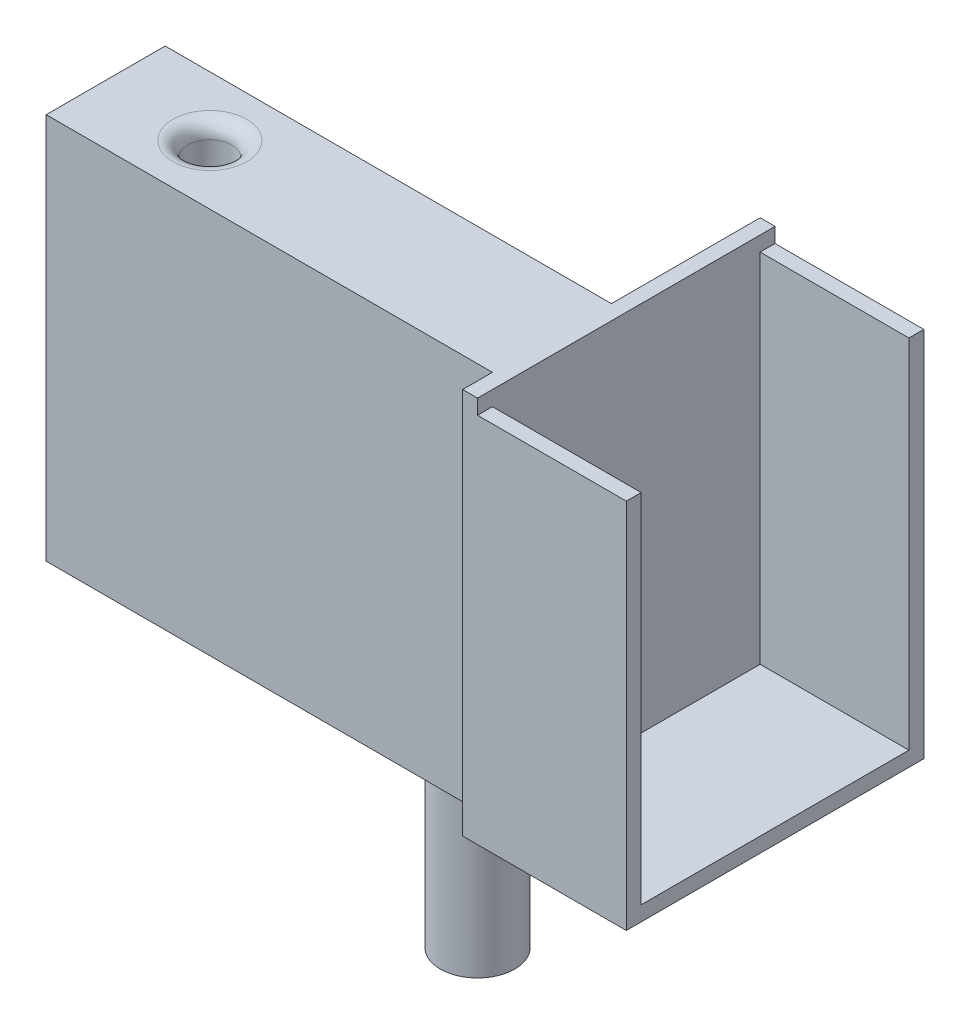
from build123d import *

# Parameters (mm, degrees)
SKETCH1_W                      = 76.2
SKETCH1_H                      = 66.04
BOSS_EXTRUDE1_DEPTH            = 20.32
SKETCH2_R                      = 3.749999993
CUT_EXTRUDE1_DEPTH             = 57.15
SKETCH4_W                      = 8
SKETCH4_H                      = 8
CUT_EXTRUDE4_DEPTH             = 5.08
FILLET2_R                      = 2.54
SKETCH5_W                      = 50.8
SKETCH5_H                      = 66.04
BOSS_EXTRUDE2_DEPTH            = 2.54
BOSS_EXTRUDE3_DEPTH            = 25.4
SKETCH3_W                      = 14
SKETCH3_H                      = 7
CUT_EXTRUDE5_DEPTH             = 73.66
CUT_EXTRUDE5_DIRECTION_2_REACH = 29.94
SKETCH7_R                      = 6.35
BOSS_EXTRUDE4_DEPTH            = 30.48


with BuildPart() as part:
    # Sketch1 → Boss-Extrude1 (new body)
    with BuildSketch(Plane.XY):
        with Locations((38.1, 33.02)):
            Rectangle(SKETCH1_W, SKETCH1_H)
    extrude(amount=BOSS_EXTRUDE1_DEPTH)

    # Sketch2 → Cut-Extrude1 (cut)
    with BuildSketch(Plane(origin=(0, 66.04, 0), x_dir=(1, 0, 0), z_dir=(0, 1, 0))):
        with Locations(Location((17.78, -10.16, 0), (0, 0, 270))):  # turned: the seam where the file's is
            Circle(SKETCH2_R)
    extrude(amount=-CUT_EXTRUDE1_DEPTH, mode=Mode.SUBTRACT)

    # Sketch4 → Cut-Extrude4 (cut)
    with BuildSketch(Plane(origin=(0, 0, 0), x_dir=(-1, 0, 0), z_dir=(0, -1, 0))):
        with Locations((-10.16, -10.16)):
            Rectangle(SKETCH4_W, SKETCH4_H)
    extrude(amount=-CUT_EXTRUDE4_DEPTH, mode=Mode.SUBTRACT)

    # Fillet2
    fillet2_edges = [part.edges().sort_by_distance(p)[0] for p in [
        (17.78, 66.04, 6.410000007),
    ]]
    fillet(fillet2_edges, radius=FILLET2_R)

    # Sketch5 → Boss-Extrude2 (add)
    with BuildSketch(Plane(origin=(76.2, 0, 0), x_dir=(0, 0, -1), z_dir=(1, 0, 0))):
        with Locations((0, 33.02)):
            Rectangle(SKETCH5_W, SKETCH5_H)
    extrude(amount=BOSS_EXTRUDE2_DEPTH)

    # Sketch6 → Boss-Extrude3 (add)
    with BuildSketch(Plane(origin=(78.74, 0, 0), x_dir=(0, 0, -1), z_dir=(1, 0, 0))):
        Polygon((-25.4, 0), (-19.631407878, 0), (15.24, 0), (25.4, 0), (25.4, 63.5), (22.86, 63.5), (22.86, 2.54), (-22.86, 2.54), (-22.86, 63.5), (-25.4, 63.5), align=None)
    extrude(amount=BOSS_EXTRUDE3_DEPTH)

    # Sketch3 → Cut-Extrude5 (cut)
    with BuildSketch(Plane(origin=(76.2, 0, 0), x_dir=(0, 0, -1), z_dir=(1, 0, 0))):
        with Locations((-10.16, 8.58)):
            Rectangle(SKETCH3_W, SKETCH3_H)
    extrude(amount=-CUT_EXTRUDE5_DEPTH, mode=Mode.SUBTRACT)

    # Sketch3 → Cut-Extrude5 direction 2 (cut, up to next)
    with BuildSketch(Plane(origin=(76.2, 0, 0), x_dir=(0, 0, -1), z_dir=(1, 0, 0)), mode=Mode.PRIVATE) as cut_extrude5_direction_2_sk1:
        with Locations((-10.16, 8.58)):
            Rectangle(SKETCH3_W, SKETCH3_H)
    cut_extrude5_direction_2_tool1 = extrude(cut_extrude5_direction_2_sk1.sketch, amount=CUT_EXTRUDE5_DIRECTION_2_REACH, mode=Mode.PRIVATE) & part.part
    add(cut_extrude5_direction_2_tool1.solids().sort_by_distance((76.2, 8.58, 10.16))[0], mode=Mode.SUBTRACT)

    # Sketch7 → Boss-Extrude4 (add)
    with BuildSketch(Plane(origin=(0, 0, 0), x_dir=(-1, 0, 0), z_dir=(0, -1, 0))):
        with Locations(Location((-63.5, -10.16, 0), (0, 0, 270))):  # turned: the seam where the file's is
            Circle(SKETCH7_R)
    extrude(amount=BOSS_EXTRUDE4_DEPTH)


solid = part.part
